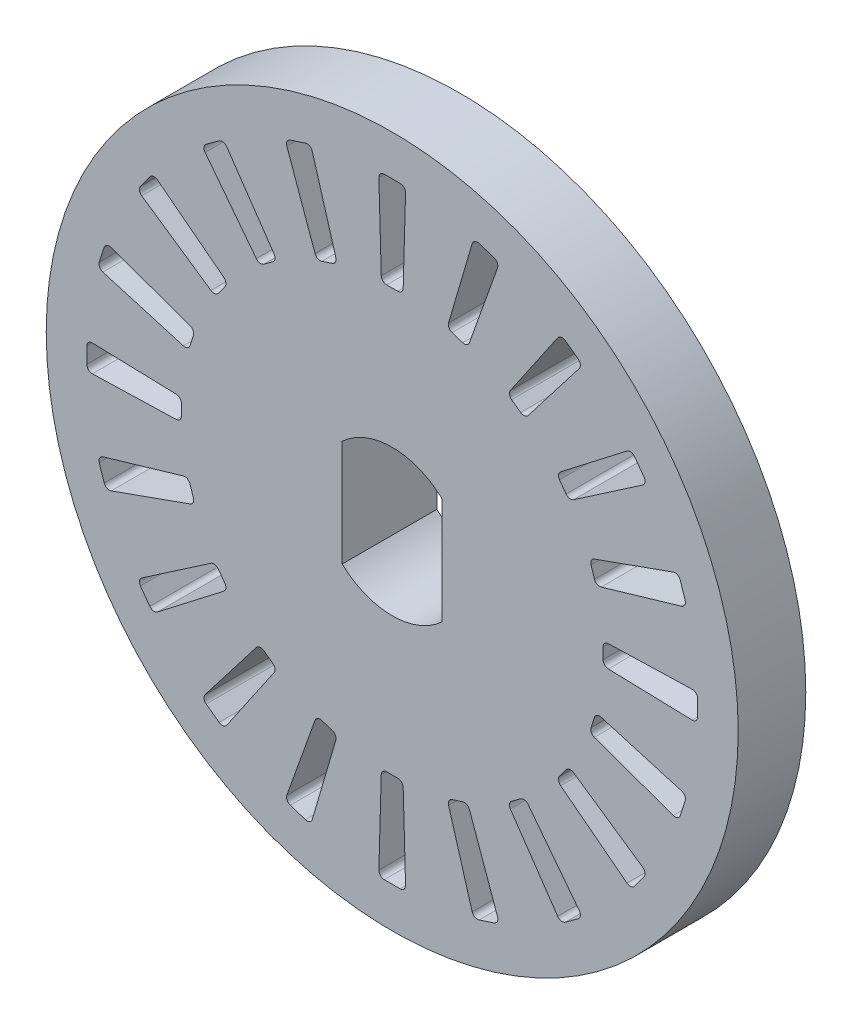
from build123d import *

# Parameters (mm, degrees)
CROQUIS1_R              = 12.8
SALIENTE_EXTRUIR1_DEPTH = 2.5
CORTAR_EXTRUIR1_DEPTH   = 7.5
SALIENTE_EXTRUIR2_DEPTH = 1


with BuildPart() as part:
    # Croquis1 → Saliente-Extruir1 (new body)
    with BuildSketch(Plane.XY):
        Circle(CROQUIS1_R)
        with BuildLine():
            Line((1.85, -1.966596044), (1.85, 1.966596044))
            ThreePointArc((1.85, 1.966596044), (0, 2.7), (-1.85, 1.966596044))
            Line((-1.85, 1.966596044), (-1.85, -1.966596044))
            ThreePointArc((-1.85, -1.966596044), (0, -2.7), (1.85, -1.966596044))
        make_face(mode=Mode.SUBTRACT)
    extrude(amount=SALIENTE_EXTRUIR1_DEPTH)

    # Croquis2 → Cortar-Extruir1 (cut)
    with BuildSketch(Plane.XY):
        with BuildLine():
            Line((0.20563267, 7.8), (-0.20563267, 7.8))
            ThreePointArc((-0.20563267, 7.8), (-0.345019916, 7.856573379), (-0.405551087, 7.994288045))
            Line((-0.405551087, 7.994288045), (-0.494122516, 11.094288045))
            ThreePointArc((-0.494122516, 11.094288045), (-0.437630719, 11.239387247), (-0.294204098, 11.3))
            Line((-0.294204098, 11.3), (0.294204098, 11.3))
            ThreePointArc((0.294204098, 11.3), (0.437630719, 11.239387247), (0.494122516, 11.094288045))
            Line((0.494122516, 11.094288045), (0.405551087, 7.994288045))
            ThreePointArc((0.405551087, 7.994288045), (0.345019916, 7.856573379), (0.20563267, 7.8))
        make_face()
        with BuildLine():
            Line((2.605900847, 7.354696838), (2.214764266, 7.481784817))
            ThreePointArc((2.214764266, 7.481784817), (2.099681252, 7.578662326), (2.08466886, 7.728341917))
            Line((2.08466886, 7.728341917), (2.958385108, 10.703987194))
            ThreePointArc((2.958385108, 10.703987194), (3.056950119, 10.824527809), (3.212087312, 10.8378527))
            Line((3.212087312, 10.8378527), (3.771696761, 10.656024568))
            ThreePointArc((3.771696761, 10.656024568), (3.889373212, 10.554057151), (3.898261985, 10.398602684))
            Line((3.898261985, 10.398602684), (2.856072868, 7.477697561))
            ThreePointArc((2.856072868, 7.477697561), (2.755948131, 7.365428291), (2.605900847, 7.354696838))
        make_face()
        with BuildLine():
            Line((4.751085292, 6.189464705), (4.418364643, 6.431200407))
            ThreePointArc((4.418364643, 6.431200407), (4.33885099, 6.558899), (4.370826894, 6.705891835))
            Line((4.370826894, 6.705891835), (6.121305385, 9.265905497))
            ThreePointArc((6.121305385, 9.265905497), (6.25229538, 9.350088171), (6.403957236, 9.314820867))
            Line((6.403957236, 9.314820867), (6.879989466, 8.968963206))
            ThreePointArc((6.879989466, 8.968963206), (6.960396757, 8.835622406), (6.92081241, 8.685029642))
            Line((6.92081241, 8.685029642), (5.027022337, 6.229137939))
            ThreePointArc((5.027022337, 6.229137939), (4.897104942, 6.153303763), (4.751085292, 6.189464705))
        make_face()
        with BuildLine():
            Line((6.431200407, 4.418364643), (6.189464705, 4.751085292))
            ThreePointArc((6.189464705, 4.751085292), (6.153303763, 4.897104942), (6.229137939, 5.027022337))
            Line((6.229137939, 5.027022337), (8.685029642, 6.92081241))
            ThreePointArc((8.685029642, 6.92081241), (8.835622406, 6.960396757), (8.968963206, 6.879989466))
            Line((8.968963206, 6.879989466), (9.314820867, 6.403957236))
            ThreePointArc((9.314820867, 6.403957236), (9.350088171, 6.25229538), (9.265905497, 6.121305385))
            Line((9.265905497, 6.121305385), (6.705891835, 4.370826894))
            ThreePointArc((6.705891835, 4.370826894), (6.558899, 4.33885099), (6.431200407, 4.418364643))
        make_face()
        with BuildLine():
            Line((7.481784817, 2.214764266), (7.354696838, 2.605900847))
            ThreePointArc((7.354696838, 2.605900847), (7.365428291, 2.755948131), (7.477697561, 2.856072868))
            Line((7.477697561, 2.856072868), (10.398602684, 3.898261985))
            ThreePointArc((10.398602684, 3.898261985), (10.554057151, 3.889373212), (10.656024568, 3.771696761))
            Line((10.656024568, 3.771696761), (10.8378527, 3.212087312))
            ThreePointArc((10.8378527, 3.212087312), (10.824527809, 3.056950119), (10.703987194, 2.958385108))
            Line((10.703987194, 2.958385108), (7.728341917, 2.08466886))
            ThreePointArc((7.728341917, 2.08466886), (7.578662326, 2.099681252), (7.481784817, 2.214764266))
        make_face()
        with BuildLine():
            Line((7.8, -0.20563267), (7.8, 0.20563267))
            ThreePointArc((7.8, 0.20563267), (7.856573379, 0.345019916), (7.994288045, 0.405551087))
            Line((7.994288045, 0.405551087), (11.094288045, 0.494122516))
            ThreePointArc((11.094288045, 0.494122516), (11.239387247, 0.437630719), (11.3, 0.294204098))
            Line((11.3, 0.294204098), (11.3, -0.294204098))
            ThreePointArc((11.3, -0.294204098), (11.239387247, -0.437630719), (11.094288045, -0.494122516))
            Line((11.094288045, -0.494122516), (7.994288045, -0.405551087))
            ThreePointArc((7.994288045, -0.405551087), (7.856573379, -0.345019916), (7.8, -0.20563267))
        make_face()
        with BuildLine():
            Line((7.354696838, -2.605900847), (7.481784817, -2.214764266))
            ThreePointArc((7.481784817, -2.214764266), (7.578662326, -2.099681252), (7.728341917, -2.08466886))
            Line((7.728341917, -2.08466886), (10.703987194, -2.958385108))
            ThreePointArc((10.703987194, -2.958385108), (10.824527809, -3.056950119), (10.8378527, -3.212087312))
            Line((10.8378527, -3.212087312), (10.656024568, -3.771696761))
            ThreePointArc((10.656024568, -3.771696761), (10.554057151, -3.889373212), (10.398602684, -3.898261985))
            Line((10.398602684, -3.898261985), (7.477697561, -2.856072868))
            ThreePointArc((7.477697561, -2.856072868), (7.365428291, -2.755948131), (7.354696838, -2.605900847))
        make_face()
        with BuildLine():
            Line((6.189464705, -4.751085292), (6.431200407, -4.418364643))
            ThreePointArc((6.431200407, -4.418364643), (6.558899, -4.33885099), (6.705891835, -4.370826894))
            Line((6.705891835, -4.370826894), (9.265905497, -6.121305385))
            ThreePointArc((9.265905497, -6.121305385), (9.350088171, -6.25229538), (9.314820867, -6.403957236))
            Line((9.314820867, -6.403957236), (8.968963206, -6.879989466))
            ThreePointArc((8.968963206, -6.879989466), (8.835622406, -6.960396757), (8.685029642, -6.92081241))
            Line((8.685029642, -6.92081241), (6.229137939, -5.027022337))
            ThreePointArc((6.229137939, -5.027022337), (6.153303763, -4.897104942), (6.189464705, -4.751085292))
        make_face()
        with BuildLine():
            Line((4.418364643, -6.431200407), (4.751085292, -6.189464705))
            ThreePointArc((4.751085292, -6.189464705), (4.897104942, -6.153303763), (5.027022337, -6.229137939))
            Line((5.027022337, -6.229137939), (6.92081241, -8.685029642))
            ThreePointArc((6.92081241, -8.685029642), (6.960396757, -8.835622406), (6.879989466, -8.968963206))
            Line((6.879989466, -8.968963206), (6.403957236, -9.314820867))
            ThreePointArc((6.403957236, -9.314820867), (6.25229538, -9.350088171), (6.121305385, -9.265905497))
            Line((6.121305385, -9.265905497), (4.370826894, -6.705891835))
            ThreePointArc((4.370826894, -6.705891835), (4.33885099, -6.558899), (4.418364643, -6.431200407))
        make_face()
        with BuildLine():
            Line((2.214764266, -7.481784817), (2.605900847, -7.354696838))
            ThreePointArc((2.605900847, -7.354696838), (2.755948131, -7.365428291), (2.856072868, -7.477697561))
            Line((2.856072868, -7.477697561), (3.898261985, -10.398602684))
            ThreePointArc((3.898261985, -10.398602684), (3.889373212, -10.554057151), (3.771696761, -10.656024568))
            Line((3.771696761, -10.656024568), (3.212087312, -10.8378527))
            ThreePointArc((3.212087312, -10.8378527), (3.056950119, -10.824527809), (2.958385108, -10.703987194))
            Line((2.958385108, -10.703987194), (2.08466886, -7.728341917))
            ThreePointArc((2.08466886, -7.728341917), (2.099681252, -7.578662326), (2.214764266, -7.481784817))
        make_face()
        with BuildLine():
            Line((-0.20563267, -7.8), (0.20563267, -7.8))
            ThreePointArc((0.20563267, -7.8), (0.345019916, -7.856573379), (0.405551087, -7.994288045))
            Line((0.405551087, -7.994288045), (0.494122516, -11.094288045))
            ThreePointArc((0.494122516, -11.094288045), (0.437630719, -11.239387247), (0.294204098, -11.3))
            Line((0.294204098, -11.3), (-0.294204098, -11.3))
            ThreePointArc((-0.294204098, -11.3), (-0.437630719, -11.239387247), (-0.494122516, -11.094288045))
            Line((-0.494122516, -11.094288045), (-0.405551087, -7.994288045))
            ThreePointArc((-0.405551087, -7.994288045), (-0.345019916, -7.856573379), (-0.20563267, -7.8))
        make_face()
        with BuildLine():
            Line((-2.605900847, -7.354696838), (-2.214764266, -7.481784817))
            ThreePointArc((-2.214764266, -7.481784817), (-2.099681252, -7.578662326), (-2.08466886, -7.728341917))
            Line((-2.08466886, -7.728341917), (-2.958385108, -10.703987194))
            ThreePointArc((-2.958385108, -10.703987194), (-3.056950119, -10.824527809), (-3.212087312, -10.8378527))
            Line((-3.212087312, -10.8378527), (-3.771696761, -10.656024568))
            ThreePointArc((-3.771696761, -10.656024568), (-3.889373212, -10.554057151), (-3.898261985, -10.398602684))
            Line((-3.898261985, -10.398602684), (-2.856072868, -7.477697561))
            ThreePointArc((-2.856072868, -7.477697561), (-2.755948131, -7.365428291), (-2.605900847, -7.354696838))
        make_face()
        with BuildLine():
            Line((-4.751085292, -6.189464705), (-4.418364643, -6.431200407))
            ThreePointArc((-4.418364643, -6.431200407), (-4.33885099, -6.558899), (-4.370826894, -6.705891835))
            Line((-4.370826894, -6.705891835), (-6.121305385, -9.265905497))
            ThreePointArc((-6.121305385, -9.265905497), (-6.25229538, -9.350088171), (-6.403957236, -9.314820867))
            Line((-6.403957236, -9.314820867), (-6.879989466, -8.968963206))
            ThreePointArc((-6.879989466, -8.968963206), (-6.960396757, -8.835622406), (-6.92081241, -8.685029642))
            Line((-6.92081241, -8.685029642), (-5.027022337, -6.229137939))
            ThreePointArc((-5.027022337, -6.229137939), (-4.897104942, -6.153303763), (-4.751085292, -6.189464705))
        make_face()
        with BuildLine():
            Line((-6.431200407, -4.418364643), (-6.189464705, -4.751085292))
            ThreePointArc((-6.189464705, -4.751085292), (-6.153303763, -4.897104942), (-6.229137939, -5.027022337))
            Line((-6.229137939, -5.027022337), (-8.685029642, -6.92081241))
            ThreePointArc((-8.685029642, -6.92081241), (-8.835622406, -6.960396757), (-8.968963206, -6.879989466))
            Line((-8.968963206, -6.879989466), (-9.314820867, -6.403957236))
            ThreePointArc((-9.314820867, -6.403957236), (-9.350088171, -6.25229538), (-9.265905497, -6.121305385))
            Line((-9.265905497, -6.121305385), (-6.705891835, -4.370826894))
            ThreePointArc((-6.705891835, -4.370826894), (-6.558899, -4.33885099), (-6.431200407, -4.418364643))
        make_face()
        with BuildLine():
            Line((-7.481784817, -2.214764266), (-7.354696838, -2.605900847))
            ThreePointArc((-7.354696838, -2.605900847), (-7.365428291, -2.755948131), (-7.477697561, -2.856072868))
            Line((-7.477697561, -2.856072868), (-10.398602684, -3.898261985))
            ThreePointArc((-10.398602684, -3.898261985), (-10.554057151, -3.889373212), (-10.656024568, -3.771696761))
            Line((-10.656024568, -3.771696761), (-10.8378527, -3.212087312))
            ThreePointArc((-10.8378527, -3.212087312), (-10.824527809, -3.056950119), (-10.703987194, -2.958385108))
            Line((-10.703987194, -2.958385108), (-7.728341917, -2.08466886))
            ThreePointArc((-7.728341917, -2.08466886), (-7.578662326, -2.099681252), (-7.481784817, -2.214764266))
        make_face()
        with BuildLine():
            Line((-7.8, 0.20563267), (-7.8, -0.20563267))
            ThreePointArc((-7.8, -0.20563267), (-7.856573379, -0.345019916), (-7.994288045, -0.405551087))
            Line((-7.994288045, -0.405551087), (-11.094288045, -0.494122516))
            ThreePointArc((-11.094288045, -0.494122516), (-11.239387247, -0.437630719), (-11.3, -0.294204098))
            Line((-11.3, -0.294204098), (-11.3, 0.294204098))
            ThreePointArc((-11.3, 0.294204098), (-11.239387247, 0.437630719), (-11.094288045, 0.494122516))
            Line((-11.094288045, 0.494122516), (-7.994288045, 0.405551087))
            ThreePointArc((-7.994288045, 0.405551087), (-7.856573379, 0.345019916), (-7.8, 0.20563267))
        make_face()
        with BuildLine():
            Line((-7.354696838, 2.605900847), (-7.481784817, 2.214764266))
            ThreePointArc((-7.481784817, 2.214764266), (-7.578662326, 2.099681252), (-7.728341917, 2.08466886))
            Line((-7.728341917, 2.08466886), (-10.703987194, 2.958385108))
            ThreePointArc((-10.703987194, 2.958385108), (-10.824527809, 3.056950119), (-10.8378527, 3.212087312))
            Line((-10.8378527, 3.212087312), (-10.656024568, 3.771696761))
            ThreePointArc((-10.656024568, 3.771696761), (-10.554057151, 3.889373212), (-10.398602684, 3.898261985))
            Line((-10.398602684, 3.898261985), (-7.477697561, 2.856072868))
            ThreePointArc((-7.477697561, 2.856072868), (-7.365428291, 2.755948131), (-7.354696838, 2.605900847))
        make_face()
        with BuildLine():
            Line((-6.189464705, 4.751085292), (-6.431200407, 4.418364643))
            ThreePointArc((-6.431200407, 4.418364643), (-6.558899, 4.33885099), (-6.705891835, 4.370826894))
            Line((-6.705891835, 4.370826894), (-9.265905497, 6.121305385))
            ThreePointArc((-9.265905497, 6.121305385), (-9.350088171, 6.25229538), (-9.314820867, 6.403957236))
            Line((-9.314820867, 6.403957236), (-8.968963206, 6.879989466))
            ThreePointArc((-8.968963206, 6.879989466), (-8.835622406, 6.960396757), (-8.685029642, 6.92081241))
            Line((-8.685029642, 6.92081241), (-6.229137939, 5.027022337))
            ThreePointArc((-6.229137939, 5.027022337), (-6.153303763, 4.897104942), (-6.189464705, 4.751085292))
        make_face()
        with BuildLine():
            Line((-4.418364643, 6.431200407), (-4.751085292, 6.189464705))
            ThreePointArc((-4.751085292, 6.189464705), (-4.897104942, 6.153303763), (-5.027022337, 6.229137939))
            Line((-5.027022337, 6.229137939), (-6.92081241, 8.685029642))
            ThreePointArc((-6.92081241, 8.685029642), (-6.960396757, 8.835622406), (-6.879989466, 8.968963206))
            Line((-6.879989466, 8.968963206), (-6.403957236, 9.314820867))
            ThreePointArc((-6.403957236, 9.314820867), (-6.25229538, 9.350088171), (-6.121305385, 9.265905497))
            Line((-6.121305385, 9.265905497), (-4.370826894, 6.705891835))
            ThreePointArc((-4.370826894, 6.705891835), (-4.33885099, 6.558899), (-4.418364643, 6.431200407))
        make_face()
        with BuildLine():
            Line((-2.214764266, 7.481784817), (-2.605900847, 7.354696838))
            ThreePointArc((-2.605900847, 7.354696838), (-2.755948131, 7.365428291), (-2.856072868, 7.477697561))
            Line((-2.856072868, 7.477697561), (-3.898261985, 10.398602684))
            ThreePointArc((-3.898261985, 10.398602684), (-3.889373212, 10.554057151), (-3.771696761, 10.656024568))
            Line((-3.771696761, 10.656024568), (-3.212087312, 10.8378527))
            ThreePointArc((-3.212087312, 10.8378527), (-3.056950119, 10.824527809), (-2.958385108, 10.703987194))
            Line((-2.958385108, 10.703987194), (-2.08466886, 7.728341917))
            ThreePointArc((-2.08466886, 7.728341917), (-2.099681252, 7.578662326), (-2.214764266, 7.481784817))
        make_face()
    extrude(amount=CORTAR_EXTRUIR1_DEPTH, mode=Mode.SUBTRACT)

    # Croquis3 → Saliente-Extruir2 (add)
    with BuildSketch(Plane(origin=(0, 0, 0), x_dir=(-1, 0, 0), z_dir=(0, 0, -1))):
        with BuildLine():
            Line((2.85, -2.359555043), (2.85, 2.359555043))
            ThreePointArc((2.85, 2.359555043), (0, 3.7), (-2.85, 2.359555043))
            Line((-2.85, 2.359555043), (-2.85, -2.359555043))
            ThreePointArc((-2.85, -2.359555043), (0, -3.7), (2.85, -2.359555043))
        make_face()
        with BuildLine():
            Line((1.85, -1.966596044), (1.85, 1.966596044))
            ThreePointArc((1.85, 1.966596044), (0, 2.7), (-1.85, 1.966596044))
            Line((-1.85, 1.966596044), (-1.85, -1.966596044))
            ThreePointArc((-1.85, -1.966596044), (0, -2.7), (1.85, -1.966596044))
        make_face(mode=Mode.SUBTRACT)
    extrude(amount=SALIENTE_EXTRUIR2_DEPTH)


solid = part.part
